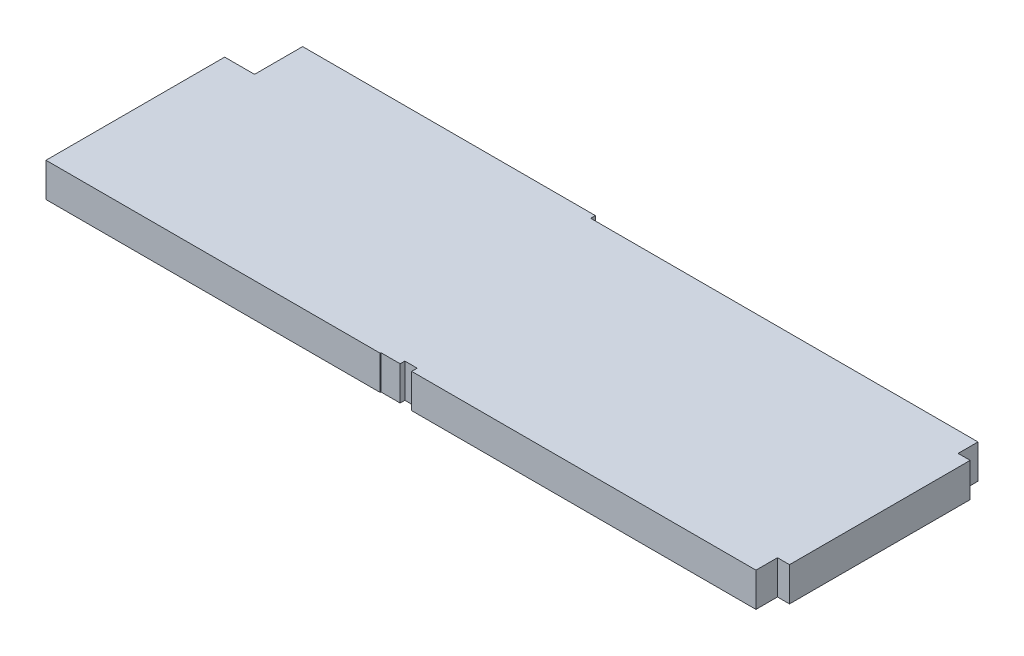
from build123d import *

# Parameters (mm, degrees)
BOSS_EXTRUDE1_DEPTH = 14.47


with BuildPart() as part:
    # Sketch1 → Boss-Extrude1 (new body)
    with BuildSketch(Plane(origin=(0, 0, 0), x_dir=(1, 0, 0), z_dir=(0, 1, 0))):
        Polygon((0, 0), (0, 75.95), (12.7, 75.95), (12.7, 96.4), (137.15, 96.4), (137.15, 94.4), (301.8, 94.4), (301.8, 85.95), (306.92, 85.95), (306.92, 9.15), (301.8, 9.15), (301.8, 0), (155.45, 0), (155.45, 2.35), (150.2, 2.35), (150.2, 0.35), (142.05, 0.35), (142.05, 0), align=None)
    extrude(amount=BOSS_EXTRUDE1_DEPTH)


solid = part.part
